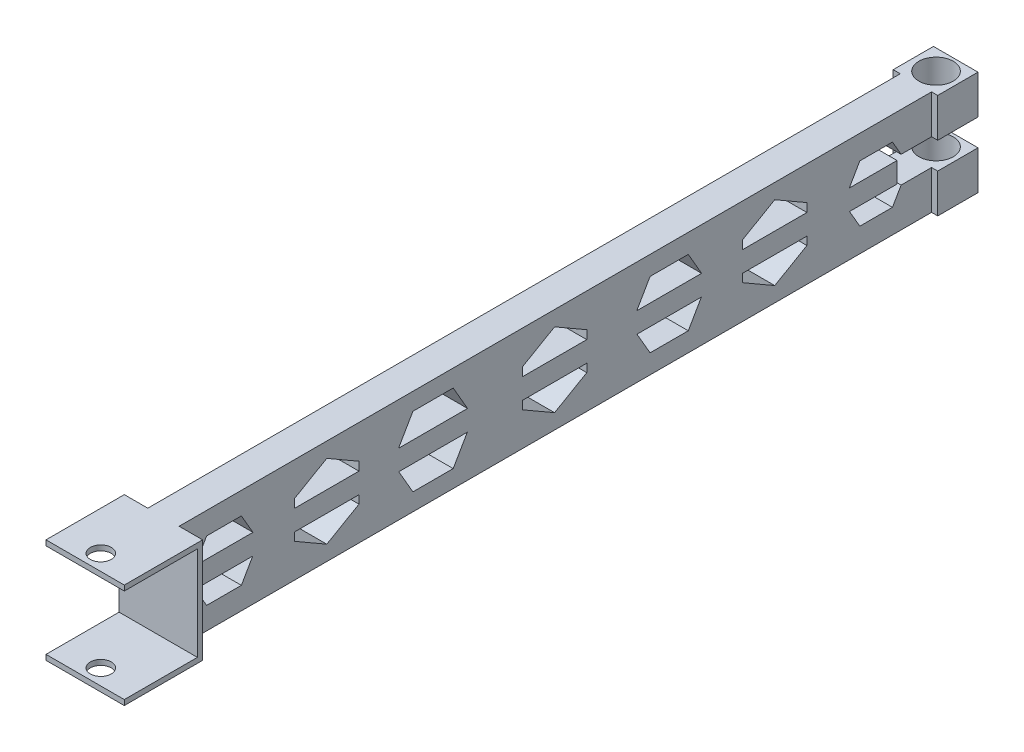
from build123d import *

# Parameters (mm, degrees)
SKETCH_1_W                      = 6
SKETCH_1_H                      = 20
EXTRUDE_1_DEPTH                 = 165
HOLE_WIZARD_G1_16_1_D           = 6.6
HOLE_WIZARD_G1_16_1_DEPTH       = 50
HOLE_WIZARD_G1_16_1_CSINK_D     = 7.773
HOLE_WIZARD_G1_16_1_CSINK_ANGLE = 90
HOLE_WIZARD_G1_16_1_TIP         = 1.982840043
EXTRUDE_2_DEPTH                 = 10
EXTRUDE_2_DEPTH_BACK            = 15
SKETCH_5_W                      = 15
SKETCH_5_H                      = 20
SKETCH_6_W                      = 4.5
SKETCH_6_H                      = 15
SKETCH_6_W_2                    = 5.5
CUT_EXTRUDE_1_DEPTH             = 32
SKETCH_7_W                      = 15
SKETCH_7_H                      = 18
CUT_EXTRUDE_2_DEPTH             = 14
SKETCH_8_R                      = 2
CUT_EXTRUDE_3_DEPTH             = 39
CUT_EXTRUDE_4_DEPTH             = 70
SKETCH_11_W                     = 8.534743408
SKETCH_11_H                     = 7.718624342
SKETCH_11_R                     = 3.3
EXTRUDE_3_DEPTH                 = 20
SKETCH_11_5_W                   = 6
SKETCH_11_5_H                   = 1.141567996
CUT_EXTRUDE_5_DEPTH             = 20
SKETCH_13_W                     = 14.331495705
SKETCH_13_H                     = 5.1
CUT_EXTRUDE_6_DEPTH             = 20


with BuildPart() as part:
    # 草图1 → 凸台-拉伸1 (new body)
    with BuildSketch(Plane.XY):
        Rectangle(SKETCH_1_W, SKETCH_1_H)
    extrude(amount=EXTRUDE_1_DEPTH)

    # G1/16 螺纹孔1
    with Locations(Plane(origin=(3, 0, 0), x_dir=(0, 0, -1), z_dir=(1, 0, 0))):
        with Locations((-5, 0)):
            CounterSinkHole(HOLE_WIZARD_G1_16_1_D / 2, HOLE_WIZARD_G1_16_1_CSINK_D / 2, depth=HOLE_WIZARD_G1_16_1_DEPTH, counter_sink_angle=HOLE_WIZARD_G1_16_1_CSINK_ANGLE)
            with Locations((0, 0, -(HOLE_WIZARD_G1_16_1_DEPTH + HOLE_WIZARD_G1_16_1_TIP / 2))):  # 118° drill point
                Cone(0, HOLE_WIZARD_G1_16_1_D / 2, HOLE_WIZARD_G1_16_1_TIP, mode=Mode.SUBTRACT)

    # 草图5 → 凸台-拉伸2 (add, two sides: drawn at the far end of the back side and taken through both)
    with BuildSketch(Plane(origin=(3, 0, 0), x_dir=(0, 0, -1), z_dir=(1, 0, 0)).offset(-EXTRUDE_2_DEPTH_BACK)):
        with Locations((-160.5, 0)):
            Rectangle(SKETCH_5_W, SKETCH_5_H)
    extrude(amount=EXTRUDE_2_DEPTH + EXTRUDE_2_DEPTH_BACK)

    # 草图6 → 切除-拉伸1 (cut)
    with BuildSketch(Plane.XZ.offset(10)):
        with Locations((-9.75, 160.5)):
            Rectangle(SKETCH_6_W, SKETCH_6_H)
        with Locations((10.25, 160.5)):
            Rectangle(SKETCH_6_W_2, SKETCH_6_H)
    extrude(amount=-CUT_EXTRUDE_1_DEPTH, mode=Mode.SUBTRACT)

    # 草图7 → 切除-拉伸2 (cut)
    with BuildSketch(Plane.XY.offset(168)):
        Rectangle(SKETCH_7_W, SKETCH_7_H)
    extrude(amount=-CUT_EXTRUDE_2_DEPTH, mode=Mode.SUBTRACT)

    # 草图8 → 切除-拉伸3 (cut)
    with BuildSketch(Plane(origin=(0, 10, 0), x_dir=(1, 0, 0), z_dir=(0, 1, 0))):
        with Locations((0, -165)):
            Circle(SKETCH_8_R)
    extrude(amount=-CUT_EXTRUDE_3_DEPTH, mode=Mode.SUBTRACT)

    # 草图9 → 切除-拉伸4 (cut)
    with BuildSketch(Plane.ZY.offset(3)):
        Polygon((138.857505266, 1.918732887), (149.946330576, 1.918732887), (147.728014723, 5.760968652), (141.075821119, 5.760968652), align=None)
        Polygon((147.728014723, -5.760968652), (149.901985563, -1.995540703), (138.901850279, -1.995540703), (141.075821119, -5.760968652), align=None)
        Polygon((118.547188397, 1.918732887), (130.875661312, 1.918732887), (130.875661312, 3.558923578), (124.711424854, 7.117847156), (118.547188397, 3.558923578), align=None)
        Polygon((130.875661312, -3.558923578), (130.875661312, -1.995540703), (118.547188397, -1.995540703), (118.547188397, -3.558923578), (124.711424854, -7.117847156), align=None)
        Polygon((97.746948796, 1.918732887), (110.964476059, 1.918732887), (108.213984717, 6.682723636), (100.497440137, 6.682723636), align=None)
        Polygon((108.213984717, -6.682723636), (110.920131045, -1.995540703), (97.791293809, -1.995540703), (100.497440137, -6.682723636), align=None)
        Polygon((74.908798357, 1.918732887), (87.237271272, 1.918732887), (87.237271272, 3.558923578), (81.073034814, 7.117847156), (74.908798357, 3.558923578), align=None)
        Polygon((87.237271272, -3.558923578), (87.237271272, -1.995540703), (74.908798357, -1.995540703), (74.908798357, -3.558923578), (81.073034814, -7.117847156), align=None)
        Polygon((52.911163907, 1.918732887), (65.330427938, 1.918732887), (62.779502404, 6.337065517), (55.46208944, 6.337065517), align=None)
        Polygon((62.779502404, -6.337065517), (65.286082924, -1.995540703), (52.95550892, -1.995540703), (55.46208944, -6.337065517), align=None)
        Polygon((32.73389091, 1.918732887), (45.062363825, 1.918732887), (45.062363825, 3.558923578), (38.898127367, 7.117847156), (32.73389091, 3.558923578), align=None)
        Polygon((45.062363825, -3.558923578), (45.062363825, -1.995540703), (32.73389091, -1.995540703), (32.73389091, -3.558923578), (38.898127367, -7.117847156), align=None)
        Polygon((14.328441006, 1.918732887), (24.619003084, 1.918732887), (22.600253038, 5.415310533), (16.347191051, 5.415310533), align=None)
        Polygon((22.600253038, -5.415310533), (24.57465807, -1.995540703), (14.372786019, -1.995540703), (16.347191051, -5.415310533), align=None)
    extrude(amount=-CUT_EXTRUDE_4_DEPTH, mode=Mode.SUBTRACT)

    # 草图11 → 凸台-拉伸3 (add)
    with BuildSketch(Plane(origin=(0, -10, 0), x_dir=(-1, 0, 0), z_dir=(0, -1, 0))):
        with Locations((0.088721547, -5.000880167)):
            Rectangle(SKETCH_11_W, SKETCH_11_H)
        with Locations((0, -5)):
            Circle(SKETCH_11_R, mode=Mode.SUBTRACT)
    extrude(amount=-EXTRUDE_3_DEPTH)

    # 草图11<5> → 切除-拉伸5 (cut)
    with BuildSketch(Plane(origin=(0, -10, 0), x_dir=(-1, 0, 0), z_dir=(0, -1, 0))):
        with Locations((0, -0.570783998)):
            Rectangle(SKETCH_11_5_W, SKETCH_11_5_H)
        with BuildLine():
            Line((3, -6.374772708), (3, -3.625227292))
            ThreePointArc((3, -3.625227292), (0, -1.7), (-3, -3.625227292))
            Line((-3, -3.625227292), (-3, -6.374772708))
            ThreePointArc((-3, -6.374772708), (0, -8.3), (3, -6.374772708))
        make_face()
    extrude(amount=-CUT_EXTRUDE_5_DEPTH, mode=Mode.SUBTRACT)

    # 草图13 → 切除-拉伸6 (cut)
    with BuildSketch(Plane(origin=(4.178650157, 0, 0), x_dir=(0, 0, -1), z_dir=(1, 0, 0))):
        with Locations((-8.307315849, 0)):
            Rectangle(SKETCH_13_W, SKETCH_13_H)
    extrude(amount=-CUT_EXTRUDE_6_DEPTH, mode=Mode.SUBTRACT)


solid = part.part
